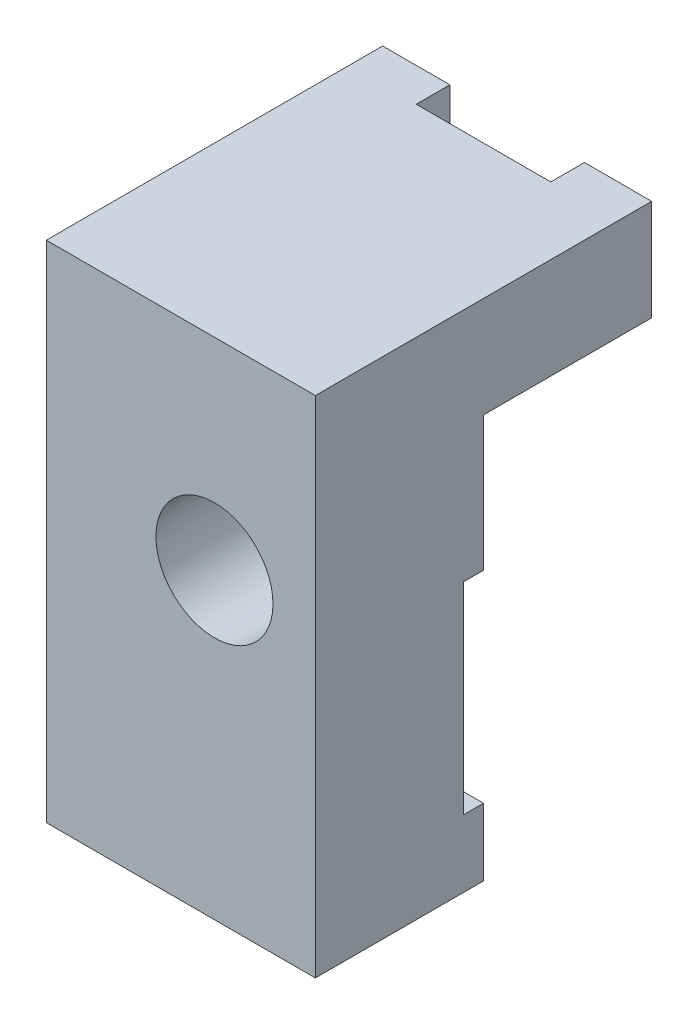
from build123d import *

# Parameters (mm, degrees)
SKETCH1_W           = 10.16
SKETCH1_H           = 19.05
BOSS_EXTRUDE1_DEPTH = 6.35
SKETCH2_W           = 6.35
SKETCH2_H           = 15.24
CUT_EXTRUDE1_DEPTH  = 11.16
SKETCH3_W           = 5.08
SKETCH3_H           = 1.27
CUT_EXTRUDE2_DEPTH  = 20.05
SKETCH4_W           = 0.762
SKETCH4_H           = 7.62
CUT_EXTRUDE3_DEPTH  = 11.16
SKETCH5_R           = 2.2098
CUT_EXTRUDE4_DEPTH  = 13.7


with BuildPart() as part:
    # Sketch1 → Boss-Extrude1 (new body, symmetric)
    with BuildSketch(Plane.XY):
        Rectangle(SKETCH1_W, SKETCH1_H)
    extrude(amount=BOSS_EXTRUDE1_DEPTH, both=True)

    # Sketch2 → Cut-Extrude1 (cut, through all)
    with BuildSketch(Plane(origin=(5.08, 0, 0), x_dir=(0, 0, -1), z_dir=(1, 0, 0))):
        with Locations((3.175, -1.905)):
            Rectangle(SKETCH2_W, SKETCH2_H)
    extrude(amount=-CUT_EXTRUDE1_DEPTH, mode=Mode.SUBTRACT)

    # Sketch3 → Cut-Extrude2 (cut, through all)
    with BuildSketch(Plane(origin=(0, 9.525, 0), x_dir=(1, 0, 0), z_dir=(0, 1, 0))):
        with Locations((0, 5.715)):
            Rectangle(SKETCH3_W, SKETCH3_H)
    extrude(amount=-CUT_EXTRUDE2_DEPTH, mode=Mode.SUBTRACT)

    # Sketch4 → Cut-Extrude3 (cut, through all)
    with BuildSketch(Plane(origin=(5.08, 0, 0), x_dir=(0, 0, -1), z_dir=(1, 0, 0))):
        with Locations((-0.381, -3.175)):
            Rectangle(SKETCH4_W, SKETCH4_H)
    extrude(amount=-CUT_EXTRUDE3_DEPTH, mode=Mode.SUBTRACT)

    # Sketch5 → Cut-Extrude4 (cut, through all)
    with BuildSketch(Plane.XY.offset(6.35)):
        with Locations((1.27, 1.905)):
            Circle(SKETCH5_R)
    extrude(amount=-CUT_EXTRUDE4_DEPTH, mode=Mode.SUBTRACT)


solid = part.part
